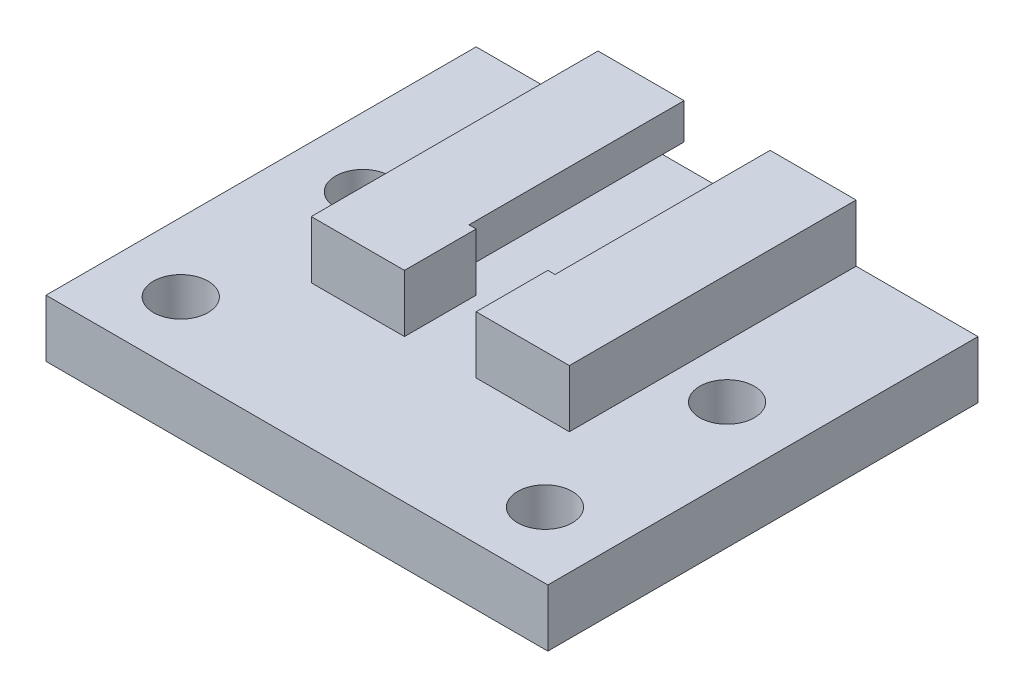
from build123d import *

# Parameters (mm, degrees)
SKETCH1_W               = 18
SKETCH1_H               = 15
BOSS_EXTRUDE1_DEPTH     = 8
SKETCH2_W               = 6
SKETCH2_H               = 2.5
SKETCH2_W_2             = 10
SKETCH2_H_2             = 2
CUT_EXTRUDE1_DEPTH      = 1
CUT_EXTRUDE1_DEPTH_BACK = 16
SKETCH4_W               = 5
SKETCH4_H               = 3.5
BOSS_EXTRUDE2_DEPTH     = 5
SKETCH5_W               = 35
SKETCH5_H               = 30
BOSS_EXTRUDE3_DEPTH     = 4
SKETCH6_R               = 1.905
CUT_EXTRUDE2_DEPTH      = 1
CUT_EXTRUDE2_DEPTH_BACK = 9


with BuildPart() as part:
    # Sketch1 → Boss-Extrude1 (new body)
    with BuildSketch(Plane(origin=(0, 0, 0), x_dir=(1, 0, 0), z_dir=(0, 1, 0))):
        with Locations((9, 7.5)):
            Rectangle(SKETCH1_W, SKETCH1_H)
    extrude(amount=BOSS_EXTRUDE1_DEPTH)

    # Sketch2 → Cut-Extrude1 (cut, two sides)
    with BuildSketch(Plane.XY) as cut_extrude1_sk:
        with Locations((9, 6.75)):
            Rectangle(SKETCH2_W, SKETCH2_H)
        with Locations((9, 4.5)):
            Rectangle(SKETCH2_W_2, SKETCH2_H_2)
    extrude(amount=CUT_EXTRUDE1_DEPTH, mode=Mode.SUBTRACT)
    extrude(cut_extrude1_sk.sketch, amount=-CUT_EXTRUDE1_DEPTH_BACK, mode=Mode.SUBTRACT)

    # Sketch4 → Boss-Extrude2 (add)
    with BuildSketch(Plane.XY):
        with Locations((9, 1.75)):
            Rectangle(SKETCH4_W, SKETCH4_H)
        Polygon((11.5, 3.5), (11.5, 0), (18, 0), (18, 8), (12, 8), (12, 5.5), (14, 5.5), (14, 3.5), align=None)
        Polygon((6, 8), (0, 8), (0, 0), (6.5, 0), (6.5, 3.5), (4, 3.5), (4, 5.5), (6, 5.5), align=None)
        Polygon((6.5, 8), (6, 8), (6, 5.5), (4, 5.5), (4, 3.5), (6.5, 3.5), align=None)
        Polygon((12, 8), (11.5, 8), (11.5, 3.5), (14, 3.5), (14, 5.5), (12, 5.5), align=None)
    extrude(amount=BOSS_EXTRUDE2_DEPTH)

    # Sketch5 → Boss-Extrude3 (add)
    with BuildSketch(Plane(origin=(0, 0, 0), x_dir=(-1, 0, 0), z_dir=(0, -1, 0))):
        with Locations((-9, 0)):
            Rectangle(SKETCH5_W, SKETCH5_H)
    extrude(amount=-BOSS_EXTRUDE3_DEPTH)

    # Sketch6 → Cut-Extrude2 (cut, two sides)
    with BuildSketch(Plane(origin=(0, 0, 0), x_dir=(-1, 0, 0), z_dir=(0, -1, 0))) as cut_extrude2_sk:
        with Locations((3.7, 2.3)):
            Circle(SKETCH6_R)
        with Locations((-21.7, -10.4)):
            Circle(SKETCH6_R)
        with Locations((3.7, -10.4)):
            Circle(SKETCH6_R)
        with Locations((-21.7, 2.3)):
            Circle(SKETCH6_R)
    extrude(amount=CUT_EXTRUDE2_DEPTH, mode=Mode.SUBTRACT)
    extrude(cut_extrude2_sk.sketch, amount=-CUT_EXTRUDE2_DEPTH_BACK, mode=Mode.SUBTRACT)


solid = part.part
